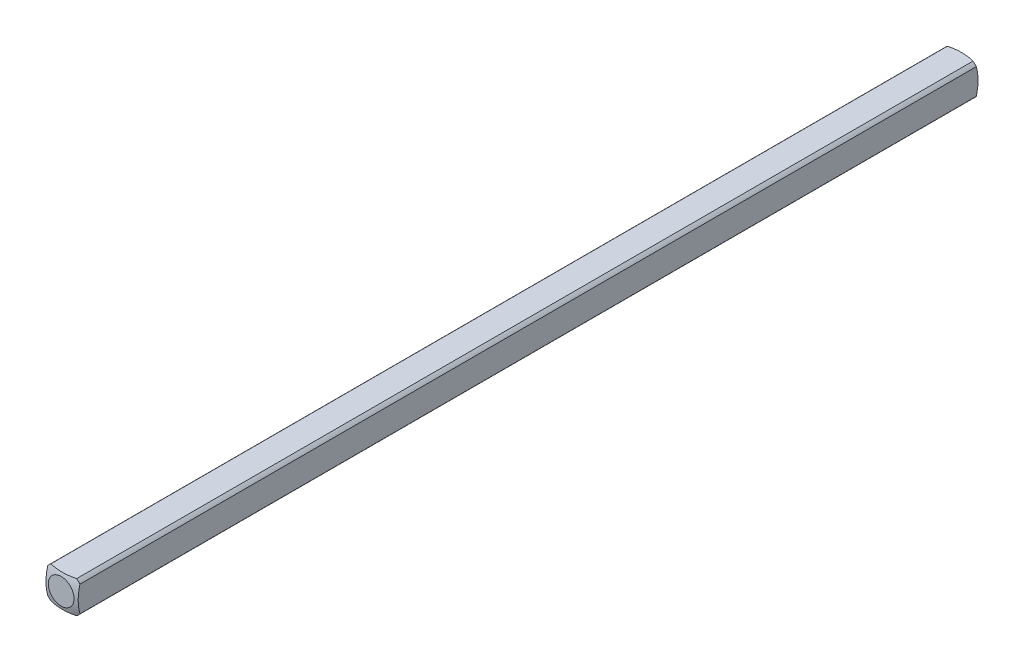
from build123d import *

# Parameters (mm, degrees)
SKETCH1_W           = 3.175
SKETCH1_H           = 3.175
BOSS_EXTRUDE1_DEPTH = 44.45
SKETCH2_OUTSIDE_W   = 14.112
SKETCH2_OUTSIDE_H   = 14.111
SKETCH2_OUTSIDE_R   = 2.032
CUT_EXTRUDE1_DEPTH  = 45.45


with BuildPart() as part:
    # Sketch1 → Boss-Extrude1 (new body)
    with BuildSketch(Plane.XY):
        Rectangle(SKETCH1_W, SKETCH1_H)
    extrude(amount=BOSS_EXTRUDE1_DEPTH)

    # Sketch2 outside → Cut-Extrude1 (cut, through all)
    with BuildSketch(Plane(origin=(0, 0, 0), x_dir=(-1, 0, 0), z_dir=(0, 0, -1))):
        with Locations((0, -0.0005)):
            Rectangle(SKETCH2_OUTSIDE_W, SKETCH2_OUTSIDE_H)
        Circle(SKETCH2_OUTSIDE_R, mode=Mode.SUBTRACT)
    extrude(amount=-CUT_EXTRUDE1_DEPTH, mode=Mode.SUBTRACT)

    # Sketch3 → Cut-Revolve1 (revolve, cut)
    with BuildSketch(Plane(origin=(0, 0, 0), x_dir=(1, 0, 0), z_dir=(0, 1, 0))):
        with BuildLine():
            Line((-5.053685963, -4.40273269), (-5.053685963, 5.740530545))
            Line((-5.053685963, 5.740530545), (0, 5.740530545))
            Line((0, 5.740530545), (0, 0.160877736))
            ThreePointArc((0, 0.160877736), (-3.404639553, -1.148866368), (-5.053685963, -4.40273269))
        make_face()
    revolve(axis=Axis((0, 0, 44.45), (0, 0, -1)), mode=Mode.SUBTRACT)

    # Mirror1: part across plane


with BuildPart() as part_1:
    add(part.part)
    add(part.part.mirror(Plane(origin=(0, 0, 44.45), x_dir=(1, 0, 0), z_dir=(0, 0, -1))))


solid = part_1.part
